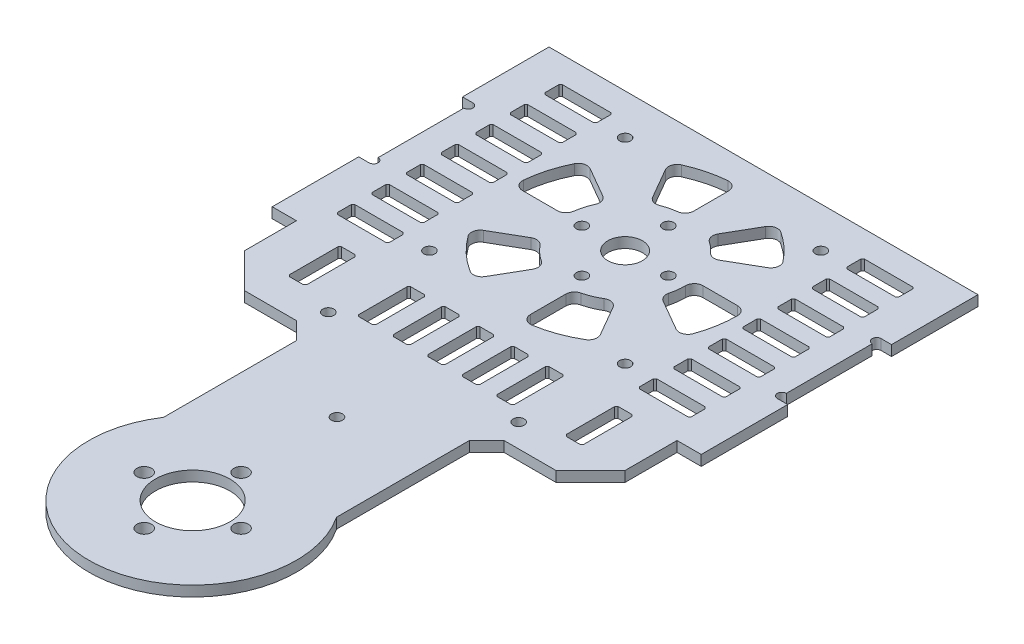
from build123d import *

# Parameters (mm, degrees)
SKETCH_1_W           = 190
SKETCH_1_H           = 80
SKETCH_1_R           = 2.1
SKETCH_1_R_2         = 1.6
SKETCH_1_R_3         = 10.75
SKETCH_1_R_4         = 5
EXTRUDE_1_DEPTH      = 3
CUT_EXTRUDE_1_REACH  = 5
SKETCH_2_R           = 1.6
CUT_EXTRUDE_2_REACH  = 5
SKETCH_3_W           = 6
SKETCH_3_H           = 30
CUT_EXTRUDE_3_REACH  = 5
SKETCH_4_R           = 1.3
CUT_EXTRUDE_4_REACH  = 5
SKETCH_5_W           = 3
SKETCH_5_H           = 30
CUT_EXTRUDE_6_REACH  = 5
SKETCH_7_R           = 1.3
CUT_EXTRUDE_7_REACH  = 5
CUT_EXTRUDE_8_REACH  = 5
EXTRUDE_START        = -3
EXTRUDE_2_DEPTH      = 3
CUT_EXTRUDE_9_REACH  = 5
SKETCH_15_R          = 10.75
SKETCH_15_R_2        = 2.1
EXTRUDE_3_DEPTH      = 3
EXTRUDE_4_DEPTH      = 3
EXTRUDE_5_DEPTH      = 3
CUT_EXTRUDE_10_REACH = 5
SKETCH_17_R          = 1.6
CUT_EXTRUDE_11_REACH = 5
SKETCH_19_R          = 1.6
CHAMFER_1_SIZE       = 10
CHAMFER_2_SIZE       = 5
CUT_EXTRUDE_12_REACH = 5


with BuildPart() as part:
    # 草图1 → 凸台-拉伸1 (new body)
    with BuildSketch(Plane(origin=(0, 0, 0), x_dir=(1, 0, 0), z_dir=(0, 1, 0))):
        with Locations((-19.5, 0)):
            Rectangle(SKETCH_1_W, SKETCH_1_H)
        with Locations((38.5, 0)):
            Circle(SKETCH_1_R, mode=Mode.SUBTRACT)
        with Locations((52.5, 14)):
            Circle(SKETCH_1_R, mode=Mode.SUBTRACT)
        with Locations((66.5, 0)):
            Circle(SKETCH_1_R, mode=Mode.SUBTRACT)
        with Locations((52.5, -14)):
            Circle(SKETCH_1_R, mode=Mode.SUBTRACT)
        with Locations((-40, 0)):
            Circle(SKETCH_1_R_2, mode=Mode.SUBTRACT)
        with Locations((-52.5, -12.5)):
            Circle(SKETCH_1_R_2, mode=Mode.SUBTRACT)
        with Locations((-65, 0)):
            Circle(SKETCH_1_R_2, mode=Mode.SUBTRACT)
        with Locations((52.5, 0)):
            Circle(SKETCH_1_R_3, mode=Mode.SUBTRACT)
        with Locations((-52.5, 0)):
            Circle(SKETCH_1_R_4, mode=Mode.SUBTRACT)
        with Locations((-52.5, 12.5)):
            Circle(SKETCH_1_R_2, mode=Mode.SUBTRACT)
    extrude(amount=EXTRUDE_1_DEPTH)

    # 草图2 → 切除-拉伸1 (cut, up to next)
    with BuildSketch(Plane(origin=(0, 3, 0), x_dir=(1, 0, 0), z_dir=(0, 1, 0)), mode=Mode.PRIVATE) as cut_extrude_1_sk1:
        with Locations((-80.784271247, 28.284271247)):
            Circle(SKETCH_2_R)
    cut_extrude_1_tool1 = extrude(cut_extrude_1_sk1.sketch, amount=-CUT_EXTRUDE_1_REACH, mode=Mode.PRIVATE) & part.part
    add(cut_extrude_1_tool1.solids().sort_by_distance((-80.784271, 3, -28.284271))[0], mode=Mode.SUBTRACT)
    # 草图2 → 切除-拉伸1 (cut, up to next)
    with BuildSketch(Plane(origin=(0, 3, 0), x_dir=(1, 0, 0), z_dir=(0, 1, 0)), mode=Mode.PRIVATE) as cut_extrude_1_sk2:
        with Locations((-80.784271247, -28.284271247)):
            Circle(SKETCH_2_R)
    cut_extrude_1_tool2 = extrude(cut_extrude_1_sk2.sketch, amount=-CUT_EXTRUDE_1_REACH, mode=Mode.PRIVATE) & part.part
    add(cut_extrude_1_tool2.solids().sort_by_distance((-80.784271, 3, 28.284271))[0], mode=Mode.SUBTRACT)
    # 草图2 → 切除-拉伸1 (cut, up to next)
    with BuildSketch(Plane(origin=(0, 3, 0), x_dir=(1, 0, 0), z_dir=(0, 1, 0)), mode=Mode.PRIVATE) as cut_extrude_1_sk3:
        with Locations((-24.215728753, -28.284271247)):
            Circle(SKETCH_2_R)
    cut_extrude_1_tool3 = extrude(cut_extrude_1_sk3.sketch, amount=-CUT_EXTRUDE_1_REACH, mode=Mode.PRIVATE) & part.part
    add(cut_extrude_1_tool3.solids().sort_by_distance((-24.215729, 3, 28.284271))[0], mode=Mode.SUBTRACT)
    # 草图2 → 切除-拉伸1 (cut, up to next)
    with BuildSketch(Plane(origin=(0, 3, 0), x_dir=(1, 0, 0), z_dir=(0, 1, 0)), mode=Mode.PRIVATE) as cut_extrude_1_sk4:
        with Locations((-24.215728753, 28.284271247)):
            Circle(SKETCH_2_R)
    cut_extrude_1_tool4 = extrude(cut_extrude_1_sk4.sketch, amount=-CUT_EXTRUDE_1_REACH, mode=Mode.PRIVATE) & part.part
    add(cut_extrude_1_tool4.solids().sort_by_distance((-24.215729, 3, -28.284271))[0], mode=Mode.SUBTRACT)

    # 草图3 → 切除-拉伸2 (cut, up to next)
    with BuildSketch(Plane(origin=(0, 3, 0), x_dir=(1, 0, 0), z_dir=(0, 1, 0)), mode=Mode.PRIVATE) as cut_extrude_2_sk1:
        with Locations((-114.5, 0)):
            Rectangle(SKETCH_3_W, SKETCH_3_H)
    cut_extrude_2_tool1 = extrude(cut_extrude_2_sk1.sketch, amount=-CUT_EXTRUDE_2_REACH, mode=Mode.PRIVATE) & part.part
    add(cut_extrude_2_tool1.solids().sort_by_distance((-114.5, 3, 0))[0], mode=Mode.SUBTRACT)

    # 草图4 → 切除-拉伸3 (cut, up to next)
    with BuildSketch(Plane(origin=(0, 3, 0), x_dir=(1, 0, 0), z_dir=(0, 1, 0)), mode=Mode.PRIVATE) as cut_extrude_3_sk1:
        with Locations((-111.5, 13.7)):
            Circle(SKETCH_4_R)
    cut_extrude_3_tool1 = extrude(cut_extrude_3_sk1.sketch, amount=-CUT_EXTRUDE_3_REACH, mode=Mode.PRIVATE) & part.part
    add(cut_extrude_3_tool1.solids().sort_by_distance((-111.5, 3, -13.7))[0], mode=Mode.SUBTRACT)
    # 草图4 → 切除-拉伸3 (cut, up to next)
    with BuildSketch(Plane(origin=(0, 3, 0), x_dir=(1, 0, 0), z_dir=(0, 1, 0)), mode=Mode.PRIVATE) as cut_extrude_3_sk2:
        with Locations((-111.5, -13.7)):
            Circle(SKETCH_4_R)
    cut_extrude_3_tool2 = extrude(cut_extrude_3_sk2.sketch, amount=-CUT_EXTRUDE_3_REACH, mode=Mode.PRIVATE) & part.part
    add(cut_extrude_3_tool2.solids().sort_by_distance((-111.5, 3, 13.7))[0], mode=Mode.SUBTRACT)

    # 草图5 → 切除-拉伸4 (cut, up to next)
    with BuildSketch(Plane(origin=(0, 3, 0), x_dir=(1, 0, 0), z_dir=(0, 1, 0)), mode=Mode.PRIVATE) as cut_extrude_4_sk1:
        with Locations((8, 0)):
            Rectangle(SKETCH_5_W, SKETCH_5_H)
    cut_extrude_4_tool1 = extrude(cut_extrude_4_sk1.sketch, amount=-CUT_EXTRUDE_4_REACH, mode=Mode.PRIVATE) & part.part
    add(cut_extrude_4_tool1.solids().sort_by_distance((8, 3, 0))[0], mode=Mode.SUBTRACT)

    # 草图7 → 切除-拉伸6 (cut, up to next)
    with BuildSketch(Plane(origin=(0, 3, 0), x_dir=(1, 0, 0), z_dir=(0, 1, 0)), mode=Mode.PRIVATE) as cut_extrude_6_sk1:
        with Locations((9.5, 13.7)):
            Circle(SKETCH_7_R)
    cut_extrude_6_tool1 = extrude(cut_extrude_6_sk1.sketch, amount=-CUT_EXTRUDE_6_REACH, mode=Mode.PRIVATE) & part.part
    add(cut_extrude_6_tool1.solids().sort_by_distance((9.5, 3, -13.7))[0], mode=Mode.SUBTRACT)
    # 草图7 → 切除-拉伸6 (cut, up to next)
    with BuildSketch(Plane(origin=(0, 3, 0), x_dir=(1, 0, 0), z_dir=(0, 1, 0)), mode=Mode.PRIVATE) as cut_extrude_6_sk2:
        with Locations((6.5, 13.7)):
            Circle(SKETCH_7_R)
    cut_extrude_6_tool2 = extrude(cut_extrude_6_sk2.sketch, amount=-CUT_EXTRUDE_6_REACH, mode=Mode.PRIVATE) & part.part
    add(cut_extrude_6_tool2.solids().sort_by_distance((6.5, 3, -13.7))[0], mode=Mode.SUBTRACT)
    # 草图7 → 切除-拉伸6 (cut, up to next)
    with BuildSketch(Plane(origin=(0, 3, 0), x_dir=(1, 0, 0), z_dir=(0, 1, 0)), mode=Mode.PRIVATE) as cut_extrude_6_sk3:
        with Locations((6.5, -13.7)):
            Circle(SKETCH_7_R)
    cut_extrude_6_tool3 = extrude(cut_extrude_6_sk3.sketch, amount=-CUT_EXTRUDE_6_REACH, mode=Mode.PRIVATE) & part.part
    add(cut_extrude_6_tool3.solids().sort_by_distance((6.5, 3, 13.7))[0], mode=Mode.SUBTRACT)
    # 草图7 → 切除-拉伸6 (cut, up to next)
    with BuildSketch(Plane(origin=(0, 3, 0), x_dir=(1, 0, 0), z_dir=(0, 1, 0)), mode=Mode.PRIVATE) as cut_extrude_6_sk4:
        with Locations((9.5, -13.7)):
            Circle(SKETCH_7_R)
    cut_extrude_6_tool4 = extrude(cut_extrude_6_sk4.sketch, amount=-CUT_EXTRUDE_6_REACH, mode=Mode.PRIVATE) & part.part
    add(cut_extrude_6_tool4.solids().sort_by_distance((9.5, 3, 13.7))[0], mode=Mode.SUBTRACT)

    # 草图8 → 切除-拉伸7 (cut, up to next)
    with BuildSketch(Plane(origin=(0, 3, 0), x_dir=(1, 0, 0), z_dir=(0, 1, 0)), mode=Mode.PRIVATE) as cut_extrude_7_sk1:
        Polygon((-103.642135624, 2), (-103.142135624, 2.5), (-89.142135624, 2.5), (-88.642135624, 2), (-88.642135624, -2), (-89.142135624, -2.5), (-103.142135624, -2.5), (-103.642135624, -2), align=None)
    cut_extrude_7_tool1 = extrude(cut_extrude_7_sk1.sketch, amount=-CUT_EXTRUDE_7_REACH, mode=Mode.PRIVATE) & part.part
    add(cut_extrude_7_tool1.solids().sort_by_distance((-96.142136, 3, 0))[0], mode=Mode.SUBTRACT)
    # 草图8 → 切除-拉伸7 (cut, up to next)
    with BuildSketch(Plane(origin=(0, 3, 0), x_dir=(1, 0, 0), z_dir=(0, 1, 0)), mode=Mode.PRIVATE) as cut_extrude_7_sk2:
        Polygon((-103.642135624, 12), (-103.642135624, 8), (-103.142135624, 7.5), (-89.142135624, 7.5), (-88.642135624, 8), (-88.642135624, 12), (-89.142135624, 12.5), (-103.142135624, 12.5), align=None)
    cut_extrude_7_tool2 = extrude(cut_extrude_7_sk2.sketch, amount=-CUT_EXTRUDE_7_REACH, mode=Mode.PRIVATE) & part.part
    add(cut_extrude_7_tool2.solids().sort_by_distance((-96.142136, 3, -10))[0], mode=Mode.SUBTRACT)
    # 草图8 → 切除-拉伸7 (cut, up to next)
    with BuildSketch(Plane(origin=(0, 3, 0), x_dir=(1, 0, 0), z_dir=(0, 1, 0)), mode=Mode.PRIVATE) as cut_extrude_7_sk3:
        Polygon((-103.642135624, 22), (-103.642135624, 18), (-103.142135624, 17.5), (-89.142135624, 17.5), (-88.642135624, 18), (-88.642135624, 22), (-89.142135624, 22.5), (-103.142135624, 22.5), align=None)
    cut_extrude_7_tool3 = extrude(cut_extrude_7_sk3.sketch, amount=-CUT_EXTRUDE_7_REACH, mode=Mode.PRIVATE) & part.part
    add(cut_extrude_7_tool3.solids().sort_by_distance((-96.142136, 3, -20))[0], mode=Mode.SUBTRACT)
    # 草图8 → 切除-拉伸7 (cut, up to next)
    with BuildSketch(Plane(origin=(0, 3, 0), x_dir=(1, 0, 0), z_dir=(0, 1, 0)), mode=Mode.PRIVATE) as cut_extrude_7_sk4:
        Polygon((-103.642135624, 32), (-103.642135624, 28), (-103.142135624, 27.5), (-89.142135624, 27.5), (-88.642135624, 28), (-88.642135624, 32), (-89.142135624, 32.5), (-103.142135624, 32.5), align=None)
    cut_extrude_7_tool4 = extrude(cut_extrude_7_sk4.sketch, amount=-CUT_EXTRUDE_7_REACH, mode=Mode.PRIVATE) & part.part
    add(cut_extrude_7_tool4.solids().sort_by_distance((-96.142136, 3, -30))[0], mode=Mode.SUBTRACT)
    # 草图8 → 切除-拉伸7 (cut, up to next)
    with BuildSketch(Plane(origin=(0, 3, 0), x_dir=(1, 0, 0), z_dir=(0, 1, 0)), mode=Mode.PRIVATE) as cut_extrude_7_sk5:
        Polygon((-103.642135624, -28), (-103.142135624, -27.5), (-89.142135624, -27.5), (-88.642135624, -28), (-88.642135624, -32), (-89.142135624, -32.5), (-103.142135624, -32.5), (-103.642135624, -32), align=None)
    cut_extrude_7_tool5 = extrude(cut_extrude_7_sk5.sketch, amount=-CUT_EXTRUDE_7_REACH, mode=Mode.PRIVATE) & part.part
    add(cut_extrude_7_tool5.solids().sort_by_distance((-96.142136, 3, 30))[0], mode=Mode.SUBTRACT)
    # 草图8 → 切除-拉伸7 (cut, up to next)
    with BuildSketch(Plane(origin=(0, 3, 0), x_dir=(1, 0, 0), z_dir=(0, 1, 0)), mode=Mode.PRIVATE) as cut_extrude_7_sk6:
        Polygon((-103.642135624, -18), (-103.142135624, -17.5), (-89.142135624, -17.5), (-88.642135624, -18), (-88.642135624, -22), (-89.142135624, -22.5), (-103.142135624, -22.5), (-103.642135624, -22), align=None)
    cut_extrude_7_tool6 = extrude(cut_extrude_7_sk6.sketch, amount=-CUT_EXTRUDE_7_REACH, mode=Mode.PRIVATE) & part.part
    add(cut_extrude_7_tool6.solids().sort_by_distance((-96.142136, 3, 20))[0], mode=Mode.SUBTRACT)
    # 草图8 → 切除-拉伸7 (cut, up to next)
    with BuildSketch(Plane(origin=(0, 3, 0), x_dir=(1, 0, 0), z_dir=(0, 1, 0)), mode=Mode.PRIVATE) as cut_extrude_7_sk7:
        Polygon((-103.642135624, -8), (-103.142135624, -7.5), (-89.142135624, -7.5), (-88.642135624, -8), (-88.642135624, -12), (-89.142135624, -12.5), (-103.142135624, -12.5), (-103.642135624, -12), align=None)
    cut_extrude_7_tool7 = extrude(cut_extrude_7_sk7.sketch, amount=-CUT_EXTRUDE_7_REACH, mode=Mode.PRIVATE) & part.part
    add(cut_extrude_7_tool7.solids().sort_by_distance((-96.142136, 3, 10))[0], mode=Mode.SUBTRACT)
    # 草图8 → 切除-拉伸7 (cut, up to next)
    with BuildSketch(Plane(origin=(0, 3, 0), x_dir=(1, 0, 0), z_dir=(0, 1, 0)), mode=Mode.PRIVATE) as cut_extrude_7_sk8:
        Polygon((-1.857864376, -32.5), (-15.857864376, -32.5), (-16.357864376, -32), (-16.357864376, -28), (-15.857864376, -27.5), (-1.857864376, -27.5), (-1.357864376, -28), (-1.357864376, -32), align=None)
    cut_extrude_7_tool8 = extrude(cut_extrude_7_sk8.sketch, amount=-CUT_EXTRUDE_7_REACH, mode=Mode.PRIVATE) & part.part
    add(cut_extrude_7_tool8.solids().sort_by_distance((-8.857864, 3, 30))[0], mode=Mode.SUBTRACT)
    # 草图8 → 切除-拉伸7 (cut, up to next)
    with BuildSketch(Plane(origin=(0, 3, 0), x_dir=(1, 0, 0), z_dir=(0, 1, 0)), mode=Mode.PRIVATE) as cut_extrude_7_sk9:
        Polygon((-1.357864376, -12), (-1.357864376, -8), (-1.857864376, -7.5), (-15.857864376, -7.5), (-16.357864376, -8), (-16.357864376, -12), (-15.857864376, -12.5), (-1.857864376, -12.5), align=None)
    cut_extrude_7_tool9 = extrude(cut_extrude_7_sk9.sketch, amount=-CUT_EXTRUDE_7_REACH, mode=Mode.PRIVATE) & part.part
    add(cut_extrude_7_tool9.solids().sort_by_distance((-8.857864, 3, 10))[0], mode=Mode.SUBTRACT)
    # 草图8 → 切除-拉伸7 (cut, up to next)
    with BuildSketch(Plane(origin=(0, 3, 0), x_dir=(1, 0, 0), z_dir=(0, 1, 0)), mode=Mode.PRIVATE) as cut_extrude_7_sk10:
        Polygon((-1.357864376, -22), (-1.357864376, -18), (-1.857864376, -17.5), (-15.857864376, -17.5), (-16.357864376, -18), (-16.357864376, -22), (-15.857864376, -22.5), (-1.857864376, -22.5), align=None)
    cut_extrude_7_tool10 = extrude(cut_extrude_7_sk10.sketch, amount=-CUT_EXTRUDE_7_REACH, mode=Mode.PRIVATE) & part.part
    add(cut_extrude_7_tool10.solids().sort_by_distance((-8.857864, 3, 20))[0], mode=Mode.SUBTRACT)
    # 草图8 → 切除-拉伸7 (cut, up to next)
    with BuildSketch(Plane(origin=(0, 3, 0), x_dir=(1, 0, 0), z_dir=(0, 1, 0)), mode=Mode.PRIVATE) as cut_extrude_7_sk11:
        Polygon((-1.357864376, 28), (-1.857864376, 27.5), (-15.857864376, 27.5), (-16.357864376, 28), (-16.357864376, 32), (-15.857864376, 32.5), (-1.857864376, 32.5), (-1.357864376, 32), align=None)
    cut_extrude_7_tool11 = extrude(cut_extrude_7_sk11.sketch, amount=-CUT_EXTRUDE_7_REACH, mode=Mode.PRIVATE) & part.part
    add(cut_extrude_7_tool11.solids().sort_by_distance((-8.857864, 3, -30))[0], mode=Mode.SUBTRACT)
    # 草图8 → 切除-拉伸7 (cut, up to next)
    with BuildSketch(Plane(origin=(0, 3, 0), x_dir=(1, 0, 0), z_dir=(0, 1, 0)), mode=Mode.PRIVATE) as cut_extrude_7_sk12:
        Polygon((-1.357864376, 18), (-1.857864376, 17.5), (-15.857864376, 17.5), (-16.357864376, 18), (-16.357864376, 22), (-15.857864376, 22.5), (-1.857864376, 22.5), (-1.357864376, 22), align=None)
    cut_extrude_7_tool12 = extrude(cut_extrude_7_sk12.sketch, amount=-CUT_EXTRUDE_7_REACH, mode=Mode.PRIVATE) & part.part
    add(cut_extrude_7_tool12.solids().sort_by_distance((-8.857864, 3, -20))[0], mode=Mode.SUBTRACT)
    # 草图8 → 切除-拉伸7 (cut, up to next)
    with BuildSketch(Plane(origin=(0, 3, 0), x_dir=(1, 0, 0), z_dir=(0, 1, 0)), mode=Mode.PRIVATE) as cut_extrude_7_sk13:
        Polygon((-1.357864376, 8), (-1.857864376, 7.5), (-15.857864376, 7.5), (-16.357864376, 8), (-16.357864376, 12), (-15.857864376, 12.5), (-1.857864376, 12.5), (-1.357864376, 12), align=None)
    cut_extrude_7_tool13 = extrude(cut_extrude_7_sk13.sketch, amount=-CUT_EXTRUDE_7_REACH, mode=Mode.PRIVATE) & part.part
    add(cut_extrude_7_tool13.solids().sort_by_distance((-8.857864, 3, -10))[0], mode=Mode.SUBTRACT)
    # 草图8 → 切除-拉伸7 (cut, up to next)
    with BuildSketch(Plane(origin=(0, 3, 0), x_dir=(1, 0, 0), z_dir=(0, 1, 0)), mode=Mode.PRIVATE) as cut_extrude_7_sk14:
        Polygon((-16.357864376, -2), (-15.857864376, -2.5), (-1.857864376, -2.5), (-1.357864376, -2), (-1.357864376, 2), (-1.857864376, 2.5), (-15.857864376, 2.5), (-16.357864376, 2), align=None)
    cut_extrude_7_tool14 = extrude(cut_extrude_7_sk14.sketch, amount=-CUT_EXTRUDE_7_REACH, mode=Mode.PRIVATE) & part.part
    add(cut_extrude_7_tool14.solids().sort_by_distance((-8.857864, 3, 0))[0], mode=Mode.SUBTRACT)

    # 草图9 → 切除-拉伸8 (cut, up to next)
    with BuildSketch(Plane(origin=(0, 3, 0), x_dir=(1, 0, 0), z_dir=(0, 1, 0)), mode=Mode.PRIVATE) as cut_extrude_8_sk1:
        with BuildLine():
            Line((-52.5, 19.843134833), (-52.5, 29.895651858))
            ThreePointArc((-52.5, 29.895651858), (-53.307491999, 31.735602038), (-55.208333333, 32.386956179))
            ThreePointArc((-55.208333333, 32.386956179), (-60.633182828, 31.465875756), (-65.82489483, 29.642826751))
            ThreePointArc((-65.82489483, 29.642826751), (-67.178919984, 28.130904699), (-66.964966429, 26.112609308))
            Line((-66.964966429, 26.112609308), (-61.926261344, 17.385316096))
            ThreePointArc((-61.926261344, 17.385316096), (-60.58978475, 16.276620753), (-58.853548105, 16.305901584))
            ThreePointArc((-58.853548105, 16.305901584), (-56.80309239, 16.962706031), (-54.6875, 17.362742979))
            ThreePointArc((-54.6875, 17.362742979), (-53.125, 18.189540264), (-52.5, 19.843134833))
        make_face()
    cut_extrude_8_tool1 = extrude(cut_extrude_8_sk1.sketch, amount=-CUT_EXTRUDE_8_REACH, mode=Mode.PRIVATE) & part.part
    add(cut_extrude_8_tool1.solids().sort_by_distance((-58.847877, 3, -24.706268))[0], mode=Mode.SUBTRACT)
    # 草图9 → 切除-拉伸8 (cut, up to next)
    with BuildSketch(Plane(origin=(0, 3, 0), x_dir=(1, 0, 0), z_dir=(0, 1, 0)), mode=Mode.PRIVATE) as cut_extrude_8_sk2:
        with BuildLine():
            Line((-43.25692933, 17.67724793), (-38.245320439, 26.357609156))
            ThreePointArc((-38.245320439, 26.357609156), (-36.659973168, 27.539466282), (-34.711945007, 27.199909919))
            ThreePointArc((-34.711945007, 27.199909919), (-30.534664391, 23.953580768), (-26.939417366, 20.072533856))
            ThreePointArc((-26.939417366, 20.072533856), (-26.450957673, 18.054517737), (-27.65561603, 16.363429281))
            Line((-27.65561603, 16.363429281), (-36.449353518, 11.286362575))
            ThreePointArc((-36.449353518, 11.286362575), (-38.084710506, 10.981304632), (-39.549434328, 11.769997824))
            ThreePointArc((-39.549434328, 11.769997824), (-40.959983131, 13.155911624), (-42.517882593, 14.373841938))
            ThreePointArc((-42.517882593, 14.373841938), (-43.531555797, 15.881434027), (-43.25692933, 17.67724793))
        make_face()
    cut_extrude_8_tool2 = extrude(cut_extrude_8_sk2.sketch, amount=-CUT_EXTRUDE_8_REACH, mode=Mode.PRIVATE) & part.part
    add(cut_extrude_8_tool2.solids().sort_by_distance((-35.367523, 3, -18.948633))[0], mode=Mode.SUBTRACT)
    # 草图9 → 切除-拉伸8 (cut, up to next)
    with BuildSketch(Plane(origin=(0, 3, 0), x_dir=(1, 0, 0), z_dir=(0, 1, 0)), mode=Mode.PRIVATE) as cut_extrude_8_sk3:
        with BuildLine():
            Line((-32.5, 2.5), (-22.5, 2.5))
            ThreePointArc((-22.5, 2.5), (-20.732233047, 1.767766953), (-20, 0))
            ThreePointArc((-20, 0), (-20.477039267, -5.547971333), (-21.894152979, -10.933074962))
            ThreePointArc((-21.894152979, -10.933074962), (-23.386387653, -12.438737131), (-25.498448904, -12.257132705))
            Line((-25.498448904, -12.257132705), (-34.376429777, -7.131428058))
            ThreePointArc((-34.376429777, -7.131428058), (-35.430901754, -5.935595641), (-35.548126055, -4.34556898))
            ThreePointArc((-35.548126055, -4.34556898), (-35.13757226, -2.190000681), (-35, 0))
            ThreePointArc((-35, 0), (-34.267766953, 1.767766953), (-32.5, 2.5))
        make_face()
    cut_extrude_8_tool3 = extrude(cut_extrude_8_sk3.sketch, amount=-CUT_EXTRUDE_8_REACH, mode=Mode.PRIVATE) & part.part
    add(cut_extrude_8_tool3.solids().sort_by_distance((-27.317148, 3, 3.979396))[0], mode=Mode.SUBTRACT)
    # 草图9 → 切除-拉伸8 (cut, up to next)
    with BuildSketch(Plane(origin=(0, 3, 0), x_dir=(1, 0, 0), z_dir=(0, 1, 0)), mode=Mode.PRIVATE) as cut_extrude_8_sk4:
        with BuildLine():
            Line((-40.073726693, -15.917049062), (-35.073344251, -24.577965509))
            ThreePointArc((-35.073344251, -24.577965509), (-34.82035695, -26.462812165), (-35.966608407, -27.980295968))
            ThreePointArc((-35.966608407, -27.980295968), (-41.455122756, -30.565678246), (-47.328526804, -32.085913809))
            ThreePointArc((-47.328526804, -32.085913809), (-49.347363884, -31.520989396), (-50.226332434, -29.617766593))
            Line((-50.226332434, -29.617766593), (-50.226332434, -19.421948872))
            ThreePointArc((-50.226332434, -19.421948872), (-49.693789056, -17.879511047), (-48.32304088, -16.994205263))
            ThreePointArc((-48.32304088, -16.994205263), (-45.848674529, -16.186718923), (-43.521441427, -15.021167929))
            ThreePointArc((-43.521441427, -15.021167929), (-41.610050502, -14.74740314), (-40.073726693, -15.917049062))
        make_face()
    cut_extrude_8_tool4 = extrude(cut_extrude_8_sk4.sketch, amount=-CUT_EXTRUDE_8_REACH, mode=Mode.PRIVATE) & part.part
    add(cut_extrude_8_tool4.solids().sort_by_distance((-43.526524, 3, 23.774085))[0], mode=Mode.SUBTRACT)
    # 草图9 → 切除-拉伸8 (cut, up to next)
    with BuildSketch(Plane(origin=(0, 3, 0), x_dir=(1, 0, 0), z_dir=(0, 1, 0)), mode=Mode.PRIVATE) as cut_extrude_8_sk5:
        with BuildLine():
            Line((-61.239055234, -18.016042897), (-66.243745824, -26.684421275))
            ThreePointArc((-66.243745824, -26.684421275), (-67.804540118, -27.860294049), (-69.734543445, -27.553956381))
            ThreePointArc((-69.734543445, -27.553956381), (-74.714407831, -23.722775654), (-78.864016057, -19.004964018))
            ThreePointArc((-78.864016057, -19.004964018), (-79.280411666, -17.018711686), (-78.086014822, -15.3779802))
            Line((-78.086014822, -15.3779802), (-69.358925859, -10.339393038))
            ThreePointArc((-69.358925859, -10.339393038), (-67.646872013, -10.047526299), (-66.157810126, -10.941399479))
            ThreePointArc((-66.157810126, -10.941399479), (-64.24834263, -12.970213778), (-62.041103901, -14.670287535))
            ThreePointArc((-62.041103901, -14.670287535), (-60.972996791, -16.183251297), (-61.239055234, -18.016042897))
        make_face()
    cut_extrude_8_tool5 = extrude(cut_extrude_8_sk5.sketch, amount=-CUT_EXTRUDE_8_REACH, mode=Mode.PRIVATE) & part.part
    add(cut_extrude_8_tool5.solids().sort_by_distance((-69.744401, 3, 18.619214))[0], mode=Mode.SUBTRACT)
    # 草图9 → 切除-拉伸8 (cut, up to next)
    with BuildSketch(Plane(origin=(0, 3, 0), x_dir=(1, 0, 0), z_dir=(0, 1, 0)), mode=Mode.PRIVATE) as cut_extrude_8_sk6:
        with BuildLine():
            Line((-72.313306424, 0.226332434), (-82.375861686, 0.226332434))
            ThreePointArc((-82.375861686, 0.226332434), (-84.222207526, 1.040803722), (-84.865516826, 2.953526804))
            ThreePointArc((-84.865516826, 2.953526804), (-83.771610946, 8.850782387), (-81.612642003, 14.44659391))
            ThreePointArc((-81.612642003, 14.44659391), (-80.095953947, 15.728565938), (-78.123208003, 15.500380965))
            Line((-78.123208003, 15.500380965), (-69.437110718, 10.485460359))
            ThreePointArc((-69.437110718, 10.485460359), (-68.305566104, 9.080821237), (-68.413721878, 7.280347243))
            ThreePointArc((-68.413721878, 7.280347243), (-69.304358824, 4.885030657), (-69.836643121, 2.38554088))
            ThreePointArc((-69.836643121, 2.38554088), (-70.670439857, 0.841925513), (-72.313306424, 0.226332434))
        make_face()
    cut_extrude_8_tool6 = extrude(cut_extrude_8_sk6.sketch, amount=-CUT_EXTRUDE_8_REACH, mode=Mode.PRIVATE) & part.part
    add(cut_extrude_8_tool6.solids().sort_by_distance((-76.947901, 3, -6.98089))[0], mode=Mode.SUBTRACT)

    # 草图10 → 凸台-拉伸2 (add)
    with BuildSketch(Plane(origin=(0, 3, 0), x_dir=(1, 0, 0), z_dir=(0, 1, 0)).offset(EXTRUDE_START)):
        with BuildLine():
            Line((29.5, 40), (75.5, 8.537218421))
            Line((75.5, 8.537218421), (75.5, -12.789646652))
            Line((75.5, -12.789646652), (29.5, -40))
            ThreePointArc((29.5, -40), (98.64108798, 0), (29.5, 40))
        make_face()
    extrude(amount=EXTRUDE_2_DEPTH)

    # 草图14 → 切除-拉伸9 (cut, up to next)
    with BuildSketch(Plane.XZ, mode=Mode.PRIVATE) as cut_extrude_9_sk1:
        Polygon((9.5, 0), (9.5, -55.787127008), (108.756331033, -55.787127008), (108.756331033, 62.279786783), (9.5, 62.279786783), align=None)
    cut_extrude_9_tool1 = extrude(cut_extrude_9_sk1.sketch, amount=-CUT_EXTRUDE_9_REACH, mode=Mode.PRIVATE) & part.part
    add(cut_extrude_9_tool1.solids().sort_by_distance((59.128166, 0, 3.24633))[0], mode=Mode.SUBTRACT)

    # 草图15 → 凸台-拉伸3 (add)
    with BuildSketch(Plane.XZ.offset(EXTRUDE_START)):
        with BuildLine():
            Line((-77.5, 40), (-77.5, 108.416876048))
            ThreePointArc((-77.5, 108.416876048), (-52.5, 155), (-27.5, 108.416876048))
            Line((-27.5, 108.416876048), (-27.5, 40))
            Line((-27.5, 40), (-77.5, 40))
        make_face()
        with Locations((-52.5, 125)):
            Circle(SKETCH_15_R, mode=Mode.SUBTRACT)
        with Locations((-66.5, 125)):
            Circle(SKETCH_15_R_2, mode=Mode.SUBTRACT)
        with Locations((-52.5, 139)):
            Circle(SKETCH_15_R_2, mode=Mode.SUBTRACT)
        with Locations((-38.5, 125)):
            Circle(SKETCH_15_R_2, mode=Mode.SUBTRACT)
        with Locations((-52.5, 111)):
            Circle(SKETCH_15_R_2, mode=Mode.SUBTRACT)
    extrude(amount=EXTRUDE_3_DEPTH)

    # 草图16 → 凸台-拉伸4 (add)
    with BuildSketch(Plane.XZ):
        Polygon((2.5, 40), (-27.5, 65), (-27.5, 40), align=None)
        Polygon((-77.5, 65), (-77.5, 40), (-107.5, 40), align=None)
    extrude(amount=-EXTRUDE_4_DEPTH)

    # 草图18 → 凸台-拉伸5 (add)
    with BuildSketch(Plane.XZ):
        Polygon((-27.5, 65), (2.5, 65), (2.5, 40), align=None)
        Polygon((-77.5, 65), (-107.5, 65), (-107.5, 40), align=None)
    extrude(amount=-EXTRUDE_5_DEPTH)

    # 草图17 → 切除-拉伸10 (cut, up to next)
    with BuildSketch(Plane.XZ, mode=Mode.PRIVATE) as cut_extrude_10_sk1:
        with Locations((-25, 58.284271247)):
            Circle(SKETCH_17_R)
    cut_extrude_10_tool1 = extrude(cut_extrude_10_sk1.sketch, amount=-CUT_EXTRUDE_10_REACH, mode=Mode.PRIVATE) & part.part
    add(cut_extrude_10_tool1.solids().sort_by_distance((-25, 0, 58.284271))[0], mode=Mode.SUBTRACT)
    # 草图17 → 切除-拉伸10 (cut, up to next)
    with BuildSketch(Plane.XZ, mode=Mode.PRIVATE) as cut_extrude_10_sk2:
        with Locations((-80, 58.284271247)):
            Circle(SKETCH_17_R)
    cut_extrude_10_tool2 = extrude(cut_extrude_10_sk2.sketch, amount=-CUT_EXTRUDE_10_REACH, mode=Mode.PRIVATE) & part.part
    add(cut_extrude_10_tool2.solids().sort_by_distance((-80, 0, 58.284271))[0], mode=Mode.SUBTRACT)

    # 草图19 → 切除-拉伸11 (cut, up to next)
    with BuildSketch(Plane.XZ, mode=Mode.PRIVATE) as cut_extrude_11_sk1:
        with Locations((-52.5, 83.284271247)):
            Circle(SKETCH_19_R)
    cut_extrude_11_tool1 = extrude(cut_extrude_11_sk1.sketch, amount=-CUT_EXTRUDE_11_REACH, mode=Mode.PRIVATE) & part.part
    add(cut_extrude_11_tool1.solids().sort_by_distance((-52.5, 0, 83.284271))[0], mode=Mode.SUBTRACT)

    # 倒角1
    chamfer_1_edges = [part.edges().sort_by_distance(p)[0] for p in [
        (2.5, 1.5, 65),
        (-107.5, 1.5, 65),
    ]]
    chamfer(chamfer_1_edges, length=CHAMFER_1_SIZE)

    # 倒角2
    chamfer_2_edges = [part.edges().sort_by_distance(p)[0] for p in [
        (-77.5, 1.5, 65),
        (-27.5, 1.5, 65),
    ]]
    chamfer(chamfer_2_edges, length=CHAMFER_2_SIZE)

    # 草图20 → 切除-拉伸12 (cut, up to next)
    with BuildSketch(Plane.XZ, mode=Mode.PRIVATE) as cut_extrude_12_sk1:
        Polygon((-50, 54.5), (-50.5, 55), (-54.5, 55), (-55, 54.5), (-55, 40.5), (-54.5, 40), (-50.5, 40), (-50, 40.5), align=None)
    cut_extrude_12_tool1 = extrude(cut_extrude_12_sk1.sketch, amount=-CUT_EXTRUDE_12_REACH, mode=Mode.PRIVATE) & part.part
    add(cut_extrude_12_tool1.solids().sort_by_distance((-52.5, 0, 47.5))[0], mode=Mode.SUBTRACT)
    # 草图20 → 切除-拉伸12 (cut, up to next)
    with BuildSketch(Plane.XZ, mode=Mode.PRIVATE) as cut_extrude_12_sk2:
        Polygon((-40, 40.5), (-40, 54.5), (-40.5, 55), (-44.5, 55), (-45, 54.5), (-45, 40.5), (-44.5, 40), (-40.5, 40), align=None)
    cut_extrude_12_tool2 = extrude(cut_extrude_12_sk2.sketch, amount=-CUT_EXTRUDE_12_REACH, mode=Mode.PRIVATE) & part.part
    add(cut_extrude_12_tool2.solids().sort_by_distance((-42.5, 0, 47.5))[0], mode=Mode.SUBTRACT)
    # 草图20 → 切除-拉伸12 (cut, up to next)
    with BuildSketch(Plane.XZ, mode=Mode.PRIVATE) as cut_extrude_12_sk3:
        Polygon((-30, 40.5), (-30, 54.5), (-30.5, 55), (-34.5, 55), (-35, 54.5), (-35, 40.5), (-34.5, 40), (-30.5, 40), align=None)
    cut_extrude_12_tool3 = extrude(cut_extrude_12_sk3.sketch, amount=-CUT_EXTRUDE_12_REACH, mode=Mode.PRIVATE) & part.part
    add(cut_extrude_12_tool3.solids().sort_by_distance((-32.5, 0, 47.5))[0], mode=Mode.SUBTRACT)
    # 草图20 → 切除-拉伸12 (cut, up to next)
    with BuildSketch(Plane.XZ, mode=Mode.PRIVATE) as cut_extrude_12_sk4:
        Polygon((-10, 40.5), (-10, 54.5), (-10.5, 55), (-14.5, 55), (-15, 54.5), (-15, 40.5), (-14.5, 40), (-10.5, 40), align=None)
    cut_extrude_12_tool4 = extrude(cut_extrude_12_sk4.sketch, amount=-CUT_EXTRUDE_12_REACH, mode=Mode.PRIVATE) & part.part
    add(cut_extrude_12_tool4.solids().sort_by_distance((-12.5, 0, 47.5))[0], mode=Mode.SUBTRACT)
    # 草图20 → 切除-拉伸12 (cut, up to next)
    with BuildSketch(Plane.XZ, mode=Mode.PRIVATE) as cut_extrude_12_sk5:
        Polygon((-64.5, 40), (-65, 40.5), (-65, 54.5), (-64.5, 55), (-60.5, 55), (-60, 54.5), (-60, 40.5), (-60.5, 40), align=None)
    cut_extrude_12_tool5 = extrude(cut_extrude_12_sk5.sketch, amount=-CUT_EXTRUDE_12_REACH, mode=Mode.PRIVATE) & part.part
    add(cut_extrude_12_tool5.solids().sort_by_distance((-62.5, 0, 47.5))[0], mode=Mode.SUBTRACT)
    # 草图20 → 切除-拉伸12 (cut, up to next)
    with BuildSketch(Plane.XZ, mode=Mode.PRIVATE) as cut_extrude_12_sk6:
        Polygon((-75, 54.5), (-74.5, 55), (-70.5, 55), (-70, 54.5), (-70, 40.5), (-70.5, 40), (-74.5, 40), (-75, 40.5), align=None)
    cut_extrude_12_tool6 = extrude(cut_extrude_12_sk6.sketch, amount=-CUT_EXTRUDE_12_REACH, mode=Mode.PRIVATE) & part.part
    add(cut_extrude_12_tool6.solids().sort_by_distance((-72.5, 0, 47.5))[0], mode=Mode.SUBTRACT)
    # 草图20 → 切除-拉伸12 (cut, up to next)
    with BuildSketch(Plane.XZ, mode=Mode.PRIVATE) as cut_extrude_12_sk7:
        Polygon((-95, 54.5), (-94.5, 55), (-90.5, 55), (-90, 54.5), (-90, 40.5), (-90.5, 40), (-94.5, 40), (-95, 40.5), align=None)
    cut_extrude_12_tool7 = extrude(cut_extrude_12_sk7.sketch, amount=-CUT_EXTRUDE_12_REACH, mode=Mode.PRIVATE) & part.part
    add(cut_extrude_12_tool7.solids().sort_by_distance((-92.5, 0, 47.5))[0], mode=Mode.SUBTRACT)


solid = part.part
